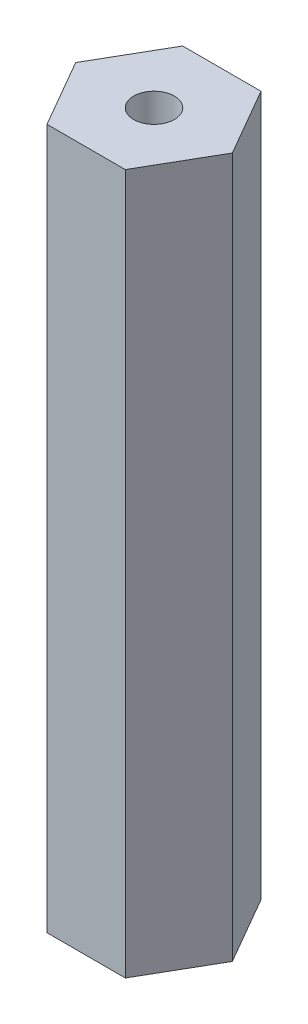
from build123d import *

# Parameters (mm, degrees)
EXTRUDE_1_DEPTH     = 25.8
SKETCH_2_R          = 0.75
CUT_EXTRUDE_1_DEPTH = 26.8


with BuildPart() as part:
    # Эскиз1 → Бобышка-Вытянуть1 (new body)
    with BuildSketch(Plane(origin=(0, 0, 0), x_dir=(1, 0, 0), z_dir=(0, 1, 0))):
        Polygon((2.886751346, 0), (1.443375673, 2.5), (-1.443375673, 2.5), (-2.886751346, 0), (-1.443375673, -2.5), (1.443375673, -2.5), align=None)
    extrude(amount=EXTRUDE_1_DEPTH)

    # Эскиз2 → Вырез-Вытянуть1 (cut, through all)
    with BuildSketch(Plane(origin=(0, 25.8, 0), x_dir=(1, 0, 0), z_dir=(0, 1, 0))):
        Circle(SKETCH_2_R)
    extrude(amount=-CUT_EXTRUDE_1_DEPTH, mode=Mode.SUBTRACT)


solid = part.part
